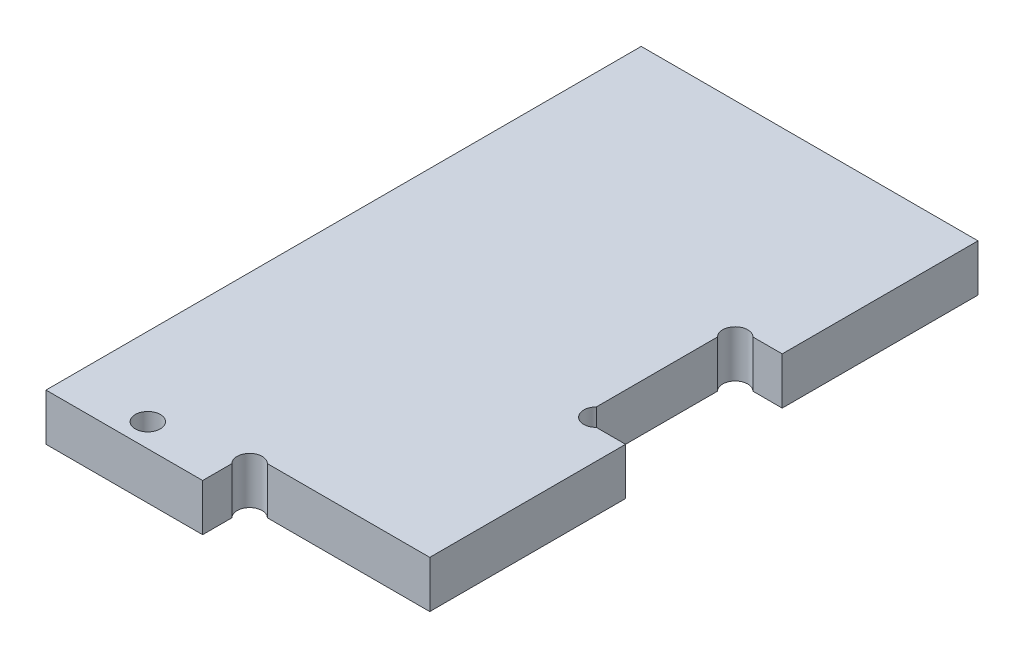
from build123d import *

# Parameters (mm, degrees)
ESQUISSE1_R        = 1.6
BOSS_EXTRU_1_DEPTH = 6


with BuildPart() as part:
    # Esquisse1 → Boss.-Extru.1 (new body)
    with BuildSketch(Plane(origin=(0, 0, 0), x_dir=(1, 0, 0), z_dir=(0, 1, 0))):
        with BuildLine():
            Line((39.2627417, 31), (43, 31))
            Line((43, 31), (43, 6))
            Line((43, 6), (22.2627417, 6))
            ThreePointArc((22.2627417, 6), (20, 6), (20, 3.7372583))
            Line((20, 3.7372583), (20, 0))
            Line((20, 0), (0, 0))
            Line((0, 0), (0, 76))
            Line((0, 76), (43, 76))
            Line((43, 76), (43, 51))
            Line((43, 51), (39.2627417, 51))
            ThreePointArc((39.2627417, 51), (37, 51), (37, 48.7372583))
            Line((37, 48.7372583), (37, 33.2627417))
            ThreePointArc((37, 33.2627417), (37, 31), (39.2627417, 31))
        make_face()
        with Locations(Location((10, 3, 0), (0, 0, 270))):  # turned: the seam where the file's is
            Circle(ESQUISSE1_R, mode=Mode.SUBTRACT)
    extrude(amount=BOSS_EXTRU_1_DEPTH)


solid = part.part
